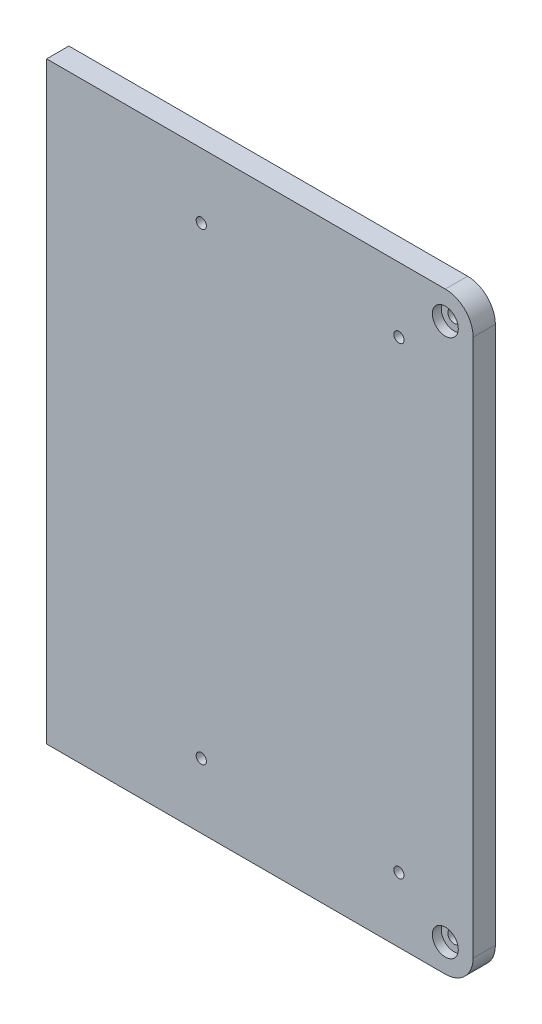
from build123d import *

# Parameters (mm, degrees)
BOSS_EXTRUDE1_DEPTH                              = 6
SKETCH4_R                                        = 1.5
CUT_EXTRUDE3_DEPTH                               = 7
SKETCH5_R                                        = 1.375
CUT_EXTRUDE4_DEPTH                               = 1
CUT_EXTRUDE4_DEPTH_BACK                          = 7
SKETCH7_R                                        = 1.5
CUT_EXTRUDE6_DEPTH                               = 7
SKETCH8_R                                        = 3
CUT_EXTRUDE7_DEPTH                               = 3.5
CBORE_FOR_M3_PAN_HEAD_MACHINE_SCREW1_D           = 3.4
CBORE_FOR_M3_PAN_HEAD_MACHINE_SCREW1_CBORE_D     = 7
CBORE_FOR_M3_PAN_HEAD_MACHINE_SCREW1_CBORE_DEPTH = 2.4
SKETCH12_W                                       = 115
SKETCH12_H                                       = 160
CUT_EXTRUDE8_DEPTH                               = 10


with BuildPart() as part:
    # Sketch1 → Boss-Extrude1 (new body)
    with BuildSketch(Plane.XY):
        with BuildLine():
            Line((-107.5, 80), (107.5, 80))
            ThreePointArc((107.5, 80), (112.803300859, 77.803300859), (115, 72.5))
            Line((115, 72.5), (115, -72.5))
            ThreePointArc((115, -72.5), (112.803300859, -77.803300859), (107.5, -80))
            Line((107.5, -80), (-107.5, -80))
            ThreePointArc((-107.5, -80), (-112.803300859, -77.803300859), (-115, -72.5))
            Line((-115, -72.5), (-115, 72.5))
            ThreePointArc((-115, 72.5), (-112.803300859, 77.803300859), (-107.5, 80))
        make_face()
    extrude(amount=BOSS_EXTRUDE1_DEPTH)

    # Sketch4 → Cut-Extrude3 (cut, through all)
    with BuildSketch(Plane.XY.offset(6)):
        with Locations((-96.5, 37.5)):
            Circle(SKETCH4_R)
        with Locations((-96.5, -37.5)):
            Circle(SKETCH4_R)
        with Locations((-24.5, 37.5)):
            Circle(SKETCH4_R)
        with Locations((-24.5, -37.5)):
            Circle(SKETCH4_R)
    extrude(amount=-CUT_EXTRUDE3_DEPTH, mode=Mode.SUBTRACT)

    # Sketch5 → Cut-Extrude4 (cut, two sides)
    with BuildSketch(Plane.XY.offset(6)) as cut_extrude4_sk:
        with Locations((95, -62.5)):
            Circle(SKETCH5_R)
        with Locations((95, 62.5)):
            Circle(SKETCH5_R)
        with Locations((41.7, -62.5)):
            Circle(SKETCH5_R)
        with Locations((41.7, 62.5)):
            Circle(SKETCH5_R)
    extrude(amount=CUT_EXTRUDE4_DEPTH, mode=Mode.SUBTRACT)
    extrude(cut_extrude4_sk.sketch, amount=-CUT_EXTRUDE4_DEPTH_BACK, mode=Mode.SUBTRACT)

    # Sketch7 → Cut-Extrude6 (cut, through all)
    with BuildSketch(Plane.XY.offset(6)):
        with Locations((-102.8, 42.3)):
            Circle(SKETCH7_R)
        with Locations((-102.8, -42.3)):
            Circle(SKETCH7_R)
        with Locations((-18.2, -42.3)):
            Circle(SKETCH7_R)
        with Locations((-18.2, 42.3)):
            Circle(SKETCH7_R)
    extrude(amount=-CUT_EXTRUDE6_DEPTH, mode=Mode.SUBTRACT)

    # Sketch8 → Cut-Extrude7 (cut)
    with BuildSketch(Plane(origin=(0, 0, 0), x_dir=(-1, 0, 0), z_dir=(0, 0, -1))):
        with Locations((18.2, 42.3)):
            Circle(SKETCH8_R)
        with Locations((18.2, -42.3)):
            Circle(SKETCH8_R)
        with Locations((102.8, -42.3)):
            Circle(SKETCH8_R)
        with Locations((102.8, 42.3)):
            Circle(SKETCH8_R)
    extrude(amount=-CUT_EXTRUDE7_DEPTH, mode=Mode.SUBTRACT)

    # CBORE for M3 Pan Head Machine Screw1 (through all)
    with Locations(Plane.XY.offset(6)):
        with Locations((-107.5, 72.5), (-107.5, -72.5), (107.5, -72.5), (107.5, 72.5)):
            CounterBoreHole(CBORE_FOR_M3_PAN_HEAD_MACHINE_SCREW1_D / 2, CBORE_FOR_M3_PAN_HEAD_MACHINE_SCREW1_CBORE_D / 2, CBORE_FOR_M3_PAN_HEAD_MACHINE_SCREW1_CBORE_DEPTH)

    # Sketch12 → Cut-Extrude8 (cut)
    with BuildSketch(Plane(origin=(0, 0, 0), x_dir=(-1, 0, 0), z_dir=(0, 0, -1))):
        with Locations((57.5, 0)):
            Rectangle(SKETCH12_W, SKETCH12_H)
    extrude(amount=-CUT_EXTRUDE8_DEPTH, mode=Mode.SUBTRACT)


solid = part.part
